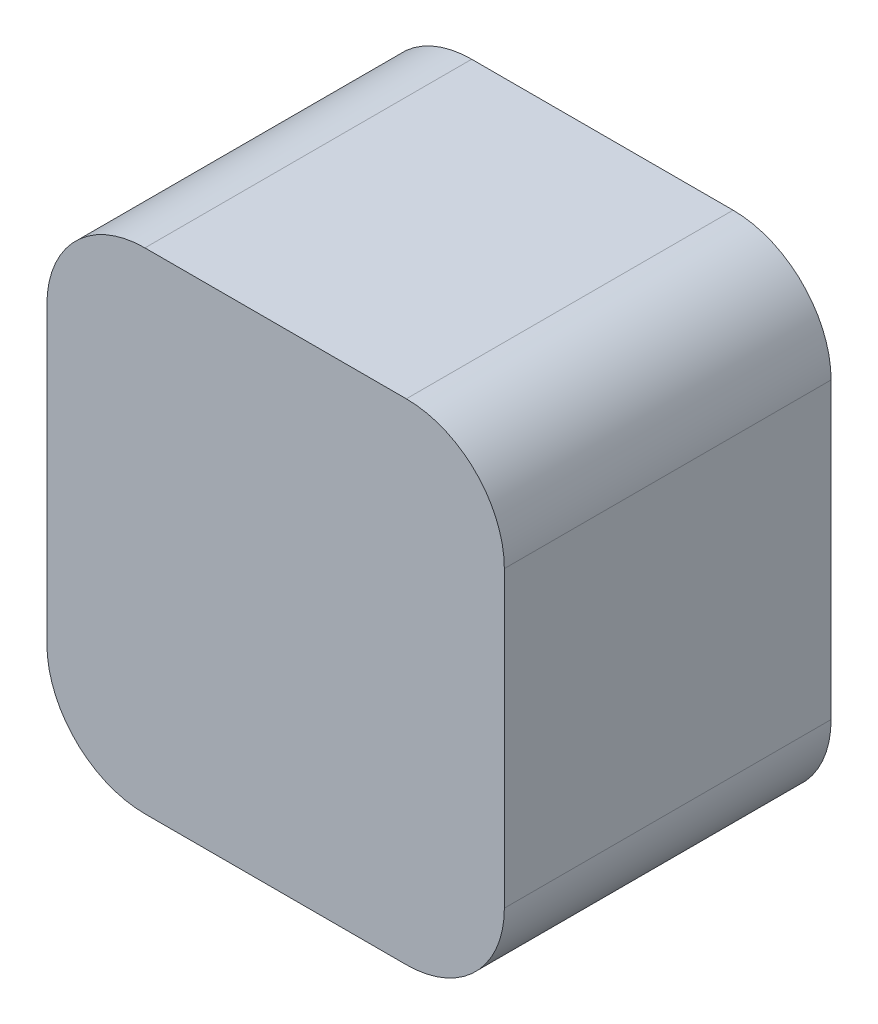
from build123d import *

# Parameters (mm, degrees)
SKETCH1_W           = 14
SKETCH1_H           = 15
BOSS_EXTRUDE1_DEPTH = 10
FILLET1_R           = 3


with BuildPart() as part:
    # Sketch1 → Boss-Extrude1 (new body)
    with BuildSketch(Plane.XY):
        with Locations((7, 7.5)):
            Rectangle(SKETCH1_W, SKETCH1_H)
    extrude(amount=BOSS_EXTRUDE1_DEPTH)

    # Fillet1
    fillet1_edges = [part.edges().sort_by_distance(p)[0] for p in [
        (0, 15, 5),
        (14, 15, 5),
        (14, 0, 5),
        (0, 0, 5),
    ]]
    fillet(fillet1_edges, radius=FILLET1_R)


solid = part.part
